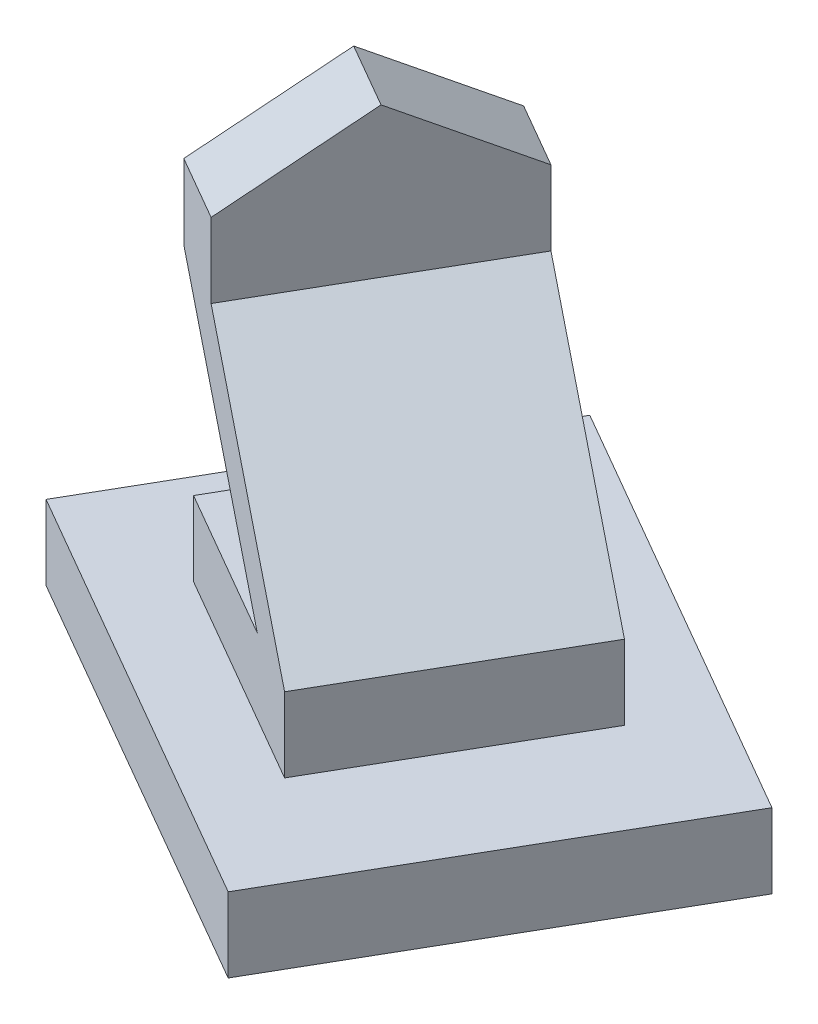
from build123d import *

# Parameters (mm, degrees)
EXTRUDE1_DEPTH = 300
EXTRUDE2_DEPTH = 300
EXTRUDE3_DEPTH = 1000
EXTRUDE4_DEPTH = 300


with BuildPart() as part:
    # Sketch1 → Extrude1 (new body)
    with BuildSketch(Plane(origin=(0, 0, 0), x_dir=(1, 0, 0), z_dir=(0, 1, 0))):
        Polygon((0, 0), (800, 1385.640646055), (-932.050807569, 2385.640646055), (-1732.050807569, 1000), align=None)
    extrude(amount=EXTRUDE1_DEPTH)

    # Sketch2 → Extrude2 (add)
    with BuildSketch(Plane(origin=(0, 300, 0), x_dir=(-1, 0, 0), z_dir=(0, 1, 0))):
        Polygon((649.038105677, -1875.83302492), (-216.987298108, -1375.83302492), (283.012701892, -509.807621135), (1149.038105677, -1009.807621135), align=None)
    extrude(amount=EXTRUDE2_DEPTH)

    # Sketch3 → Extrude3 (add)
    with BuildSketch(Plane(origin=(150, 0, -259.807621135), x_dir=(0.866025404, 0, 0.5), z_dir=(-0.5, 0, 0.866025404))):
        Polygon((-500, 600), (-1307.273555505, 1400), (-1307.273555505, 1700), (-1607.273555505, 1700), (-1607.273555505, 1400), (-800, 600), align=None)
    extrude(amount=-EXTRUDE3_DEPTH)

    # Sketch4 → Extrude4 (add)
    with BuildSketch(Plane(origin=(-1132.132108763, 0, -653.636777752), x_dir=(0.5, 0, -0.866025404), z_dir=(0.866025404, 0, 0.5))):
        Polygon((300, 1700), (1300, 1700), (800, 2000), align=None)
    extrude(amount=-EXTRUDE4_DEPTH)


solid = part.part
